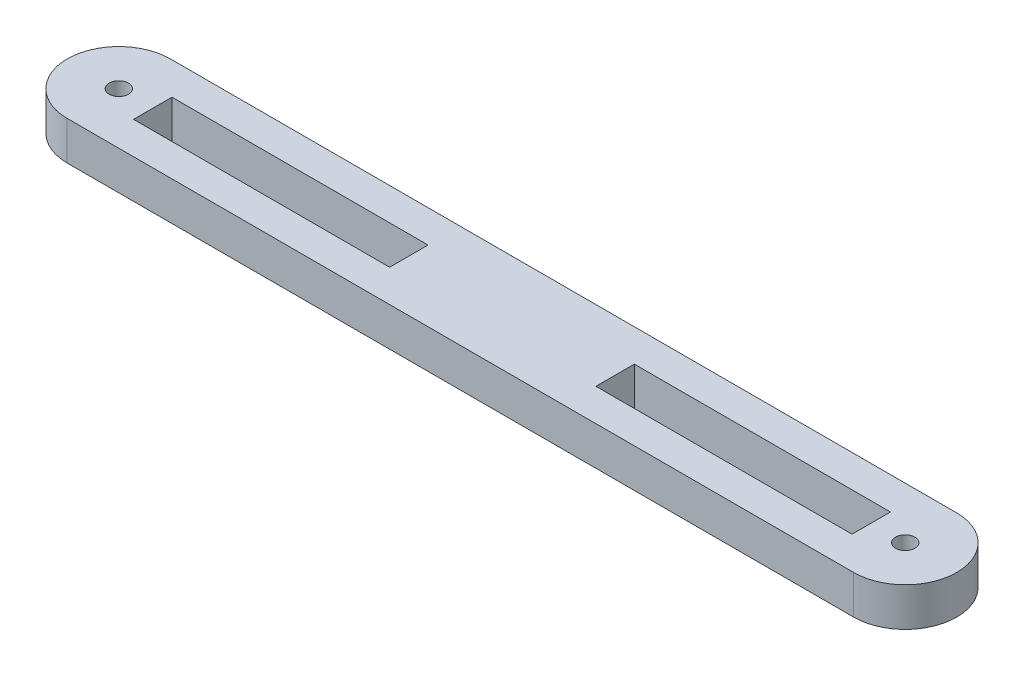
from build123d import *

# Parameters (mm, degrees)
SKETCH1_R           = 1.5
BOSS_EXTRUDE1_DEPTH = 6
SKETCH2_W           = 28.99967905
SKETCH2_H           = 5.960844098
SKETCH2_W_2         = 10.731611964
CUT_EXTRUDE1_DEPTH  = 14


with BuildPart() as part:
    # Sketch1 → Boss-Extrude1 (new body)
    with BuildSketch(Plane(origin=(0, 0, 0), x_dir=(1, 0, 0), z_dir=(0, 1, 0))):
        with BuildLine():
            Line((0, 8), (122, 8))
            ThreePointArc((122, 8), (130, 0), (122, -8))
            Line((122, -8), (0, -8))
            ThreePointArc((0, -8), (-8, 0), (0, 8))
        make_face()
        Circle(SKETCH1_R, mode=Mode.SUBTRACT)
        with Locations((122, 0)):
            Circle(SKETCH1_R, mode=Mode.SUBTRACT)
    extrude(amount=BOSS_EXTRUDE1_DEPTH)

    # Sketch2 → Cut-Extrude1 (cut)
    with BuildSketch(Plane(origin=(0, 6, 0), x_dir=(1, 0, 0), z_dir=(0, 1, 0))):
        with Locations((30.5, 0)):
            Rectangle(SKETCH2_W, SKETCH2_H)
        with Locations((10.634354493, 0)):
            Rectangle(SKETCH2_W_2, SKETCH2_H)
        Polygon((105.999839525, 2.980422049), (77.000160475, 2.980422049), (77.000160475, -2.980422049), (105.999839525, -2.980422049), (116.731451489, -2.980422049), (116.731451489, 2.980422049), align=None)
    extrude(amount=-CUT_EXTRUDE1_DEPTH, mode=Mode.SUBTRACT)


solid = part.part
